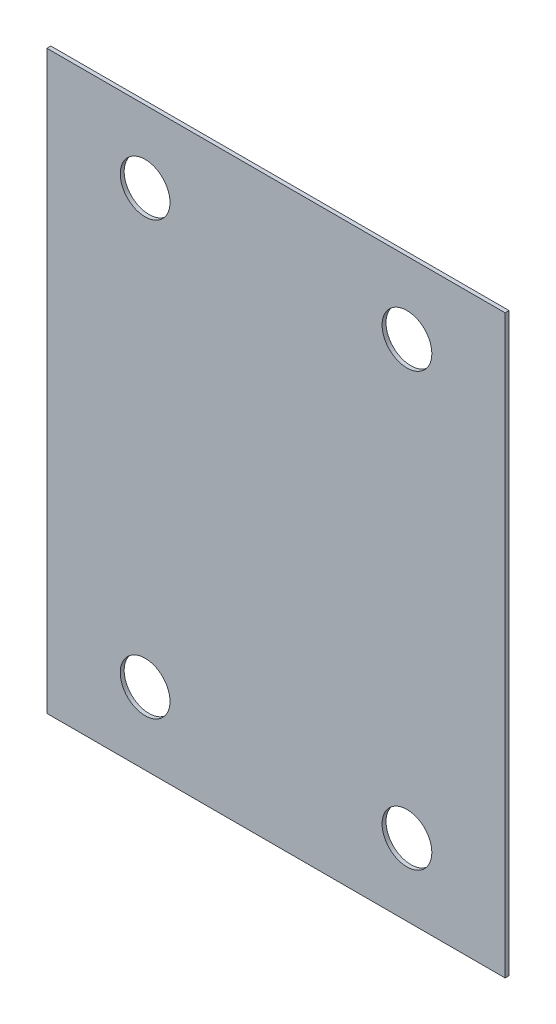
from build123d import *

# Parameters (mm, degrees)
SKETCH_1_W      = 350
SKETCH_1_H      = 440
SKETCH_1_R      = 19
EXTRUDE_1_DEPTH = 3


with BuildPart() as part:
    # Эскиз1 → Бобышка-Вытянуть1 (new body)
    with BuildSketch(Plane.XY):
        Rectangle(SKETCH_1_W, SKETCH_1_H)
        with Locations((-100, 165)):
            Circle(SKETCH_1_R, mode=Mode.SUBTRACT)
        with Locations((100, 165)):
            Circle(SKETCH_1_R, mode=Mode.SUBTRACT)
        with Locations((100, -165)):
            Circle(SKETCH_1_R, mode=Mode.SUBTRACT)
        with Locations((-100, -165)):
            Circle(SKETCH_1_R, mode=Mode.SUBTRACT)
    extrude(amount=EXTRUDE_1_DEPTH)


solid = part.part
